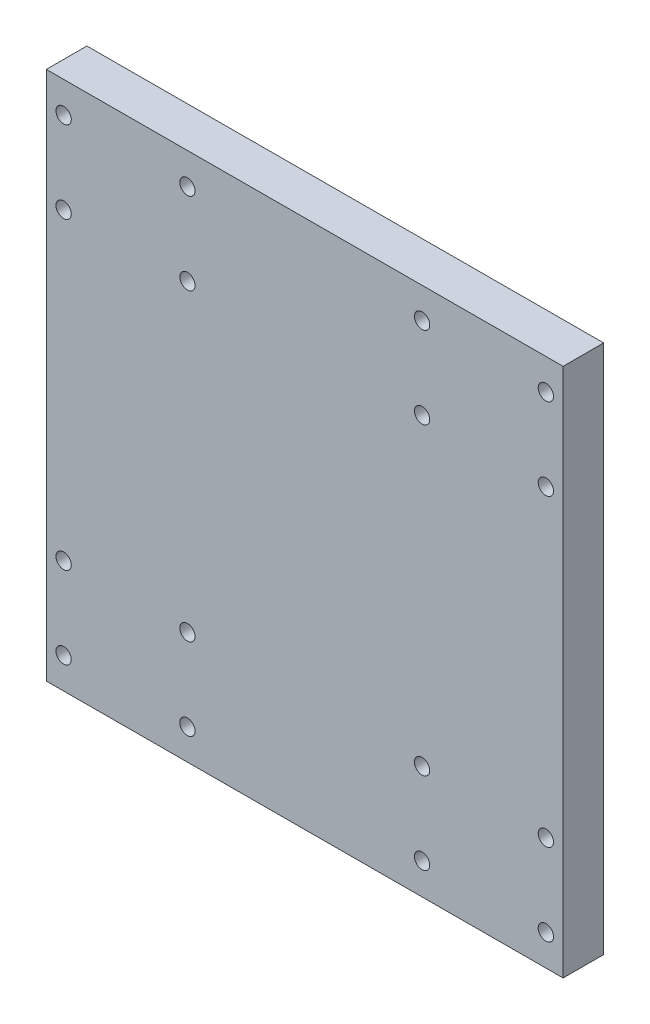
from build123d import *

# Parameters (mm, degrees)
SKETCH1_R           = 1.13211215
BOSS_EXTRUDE1_DEPTH = 5.9944


with BuildPart() as part:
    # Sketch1 → Boss-Extrude1 (new body)
    with BuildSketch(Plane.XY):
        Polygon((68.439590063, -10.224157235), (68.439590063, 68.128182765), (-8.002589937, 67.93922998), (-8.002589937, -10.41311002), align=None)
        with Locations((-5.444904937, -5.83350772)):
            Circle(SKETCH1_R, mode=Mode.SUBTRACT)
        with Locations((-5.444904937, 6.28184228)):
            Circle(SKETCH1_R, mode=Mode.SUBTRACT)
        with Locations((12.862735063, 6.28184228)):
            Circle(SKETCH1_R, mode=Mode.SUBTRACT)
        with Locations((12.862735063, -5.83350772)):
            Circle(SKETCH1_R, mode=Mode.SUBTRACT)
        with Locations((47.574265063, -5.649939535)):
            Circle(SKETCH1_R, mode=Mode.SUBTRACT)
        with Locations((47.574265063, 6.465410465)):
            Circle(SKETCH1_R, mode=Mode.SUBTRACT)
        with Locations((65.881905063, 6.465410465)):
            Circle(SKETCH1_R, mode=Mode.SUBTRACT)
        with Locations((65.881905063, -5.649939535)):
            Circle(SKETCH1_R, mode=Mode.SUBTRACT)
        with Locations((47.574265063, 51.433230465)):
            Circle(SKETCH1_R, mode=Mode.SUBTRACT)
        with Locations((47.574265063, 63.548580465)):
            Circle(SKETCH1_R, mode=Mode.SUBTRACT)
        with Locations((65.881905063, 63.548580465)):
            Circle(SKETCH1_R, mode=Mode.SUBTRACT)
        with Locations((65.881905063, 51.433230465)):
            Circle(SKETCH1_R, mode=Mode.SUBTRACT)
        with Locations((12.862735063, 51.24966228)):
            Circle(SKETCH1_R, mode=Mode.SUBTRACT)
        with Locations((12.862735063, 63.36501228)):
            Circle(SKETCH1_R, mode=Mode.SUBTRACT)
        with Locations((-5.444904937, 63.36501228)):
            Circle(SKETCH1_R, mode=Mode.SUBTRACT)
        with Locations((-5.444904937, 51.24966228)):
            Circle(SKETCH1_R, mode=Mode.SUBTRACT)
    extrude(amount=BOSS_EXTRUDE1_DEPTH)


solid = part.part
